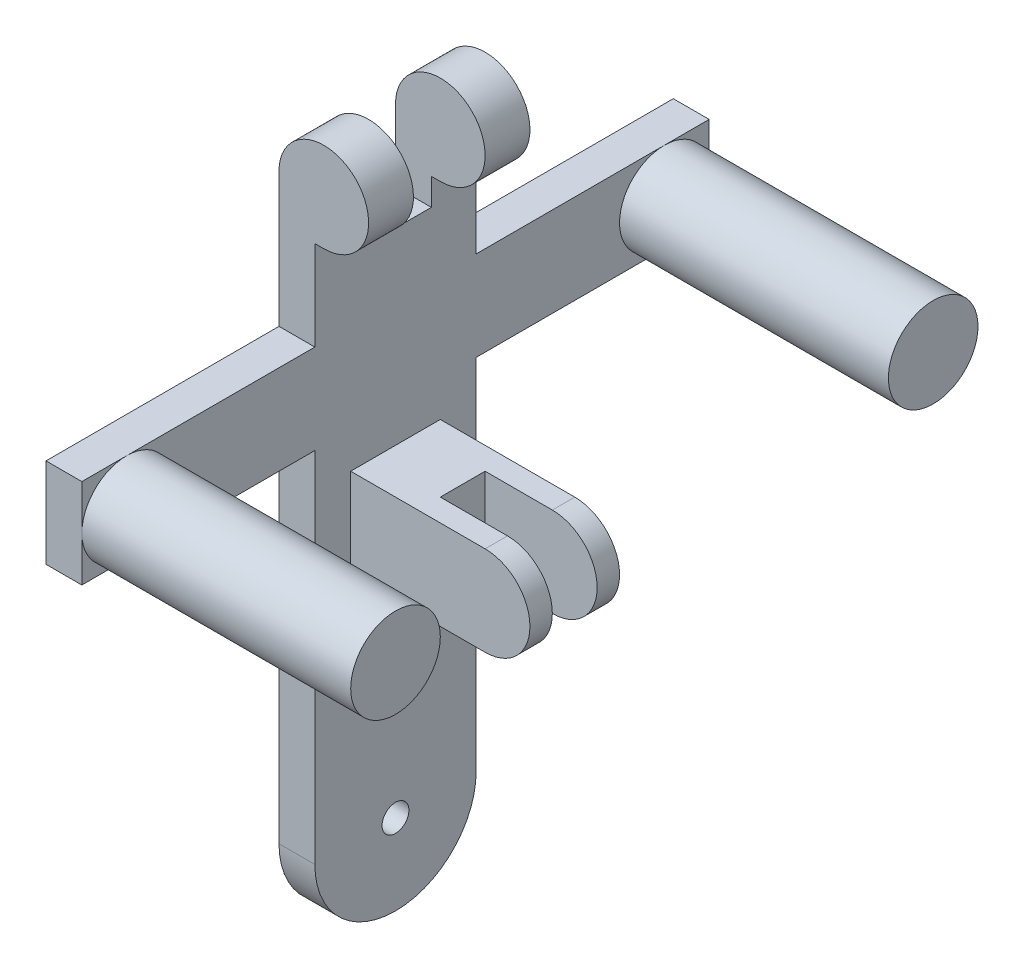
from build123d import *

# Parameters (mm, degrees)
SKETCH_1_R          = 3
EXTRUDE_1_DEPTH     = 8
SKETCH_3_W          = 12
SKETCH_3_H          = 20
EXTRUDE_2_DEPTH     = 36
SKETCH_8_R          = 10
EXTRUDE_4_DEPTH     = 60
EXTRUDE_4_2_DEPTH   = 60
CUT_EXTRUDE_1_DEPTH = 89
SKETCH_12_W         = 8
SKETCH_12_H         = 20
EXTRUDE_5_DEPTH     = 70
SKETCH_13_W         = 16
SKETCH_13_H         = 35.268464788
CUT_EXTRUDE_2_DEPTH = 140
SKETCH_14_W         = 20
SKETCH_14_H         = 20
EXTRUDE_6_DEPTH     = 40
CUT_EXTRUDE_3_DEPTH = 40
SKETCH_16_W         = 28.583727007
SKETCH_16_H         = 28.583727007
CUT_EXTRUDE_4_DEPTH = 5


with BuildPart() as part:
    # 草图1 → 凸台-拉伸1 (new body)
    with BuildSketch(Plane(origin=(0, 0, 0), x_dir=(0, 0, -1), z_dir=(1, 0, 0))):
        with BuildLine():
            Line((-18, 0), (-18, 140))
            Line((-18, 140), (18, 140))
            Line((18, 140), (18, 0))
            ThreePointArc((18, 0), (0, -18), (-18, 0))
        make_face()
        Circle(SKETCH_1_R, mode=Mode.SUBTRACT)
    extrude(amount=EXTRUDE_1_DEPTH)

    # 草图3 → 凸台-拉伸2 (add)
    with BuildSketch(Plane(origin=(0, 0, -18), x_dir=(-1, 0, 0), z_dir=(0, 0, -1))):
        with Locations((-14, 130)):
            Rectangle(SKETCH_3_W, SKETCH_3_H)
    extrude(amount=-EXTRUDE_2_DEPTH)

    # 草图10 → 切除-拉伸1 (cut, through all)
    with BuildSketch(Plane.XY.offset(18)):
        with BuildLine():
            Line((0, 130), (-3.859245882, 130))
            Line((-3.859245882, 130), (-3.859245882, 144.839572577))
            Line((-3.859245882, 144.839572577), (22.991832782, 144.839572577))
            Line((22.991832782, 144.839572577), (22.991832782, 116.883342809))
            Line((22.991832782, 116.883342809), (10, 116.883342809))
            Line((10, 116.883342809), (10, 120))
            ThreePointArc((10, 120), (17.071067812, 137.071067812), (0, 130))
        make_face()
    extrude(amount=-CUT_EXTRUDE_1_DEPTH, mode=Mode.SUBTRACT)



with BuildPart() as body_2:
    # 草图8 → 凸台-拉伸4 (new body)
    with BuildSketch(Plane(origin=(8, 0, 0), x_dir=(0, 0, -1), z_dir=(1, 0, 0))):
        with Locations((-60, 90)):
            Circle(SKETCH_8_R)
    extrude(amount=EXTRUDE_4_DEPTH)


with BuildPart() as body_3:
    # 草图8 → Extrude 4 2 (new body)
    with BuildSketch(Plane(origin=(8, 0, 0), x_dir=(0, 0, -1), z_dir=(1, 0, 0))):
        with Locations((60, 90)):
            Circle(SKETCH_8_R)
    extrude(amount=EXTRUDE_4_2_DEPTH)


with BuildPart() as part_1:
    add(part.part)

    add(body_2.part)  # 凸台-拉伸5 merges body 2

    add(body_3.part)  # 凸台-拉伸5 merges body 3
    # 草图12 → 凸台-拉伸5 (add, symmetric)
    with BuildSketch(Plane.XY):
        with Locations((4, 90)):
            Rectangle(SKETCH_12_W, SKETCH_12_H)
    extrude(amount=EXTRUDE_5_DEPTH, both=True)

    # 草图13 → 切除-拉伸2 (cut)
    with BuildSketch(Plane.ZY):
        with Locations((0, 131.634232394)):
            Rectangle(SKETCH_13_W, SKETCH_13_H)
    extrude(amount=-CUT_EXTRUDE_2_DEPTH, mode=Mode.SUBTRACT)

    # 草图14 → 凸台-拉伸6 (add)
    with BuildSketch(Plane(origin=(8, 0, 0), x_dir=(0, 0, -1), z_dir=(1, 0, 0))):
        with Locations((0, 62)):
            Rectangle(SKETCH_14_W, SKETCH_14_H)
    extrude(amount=EXTRUDE_6_DEPTH)

    # 草图15 → 切除-拉伸3 (cut)
    with BuildSketch(Plane(origin=(0, 0, -10), x_dir=(-1, 0, 0), z_dir=(0, 0, -1))):
        with BuildLine():
            Line((-38, 72), (-54.351268728, 72))
            Line((-54.351268728, 72), (-54.351268728, 52))
            Line((-54.351268728, 52), (-38, 52))
            ThreePointArc((-38, 52), (-48, 62), (-38, 72))
        make_face()
    extrude(amount=-CUT_EXTRUDE_3_DEPTH, mode=Mode.SUBTRACT)

    # 草图16 → 切除-拉伸4 (cut, symmetric)
    with BuildSketch(Plane.XY):
        with Locations((37.291863503, 60.532166911)):
            Rectangle(SKETCH_16_W, SKETCH_16_H)
    extrude(amount=CUT_EXTRUDE_4_DEPTH, both=True, mode=Mode.SUBTRACT)


solid = part_1.part
